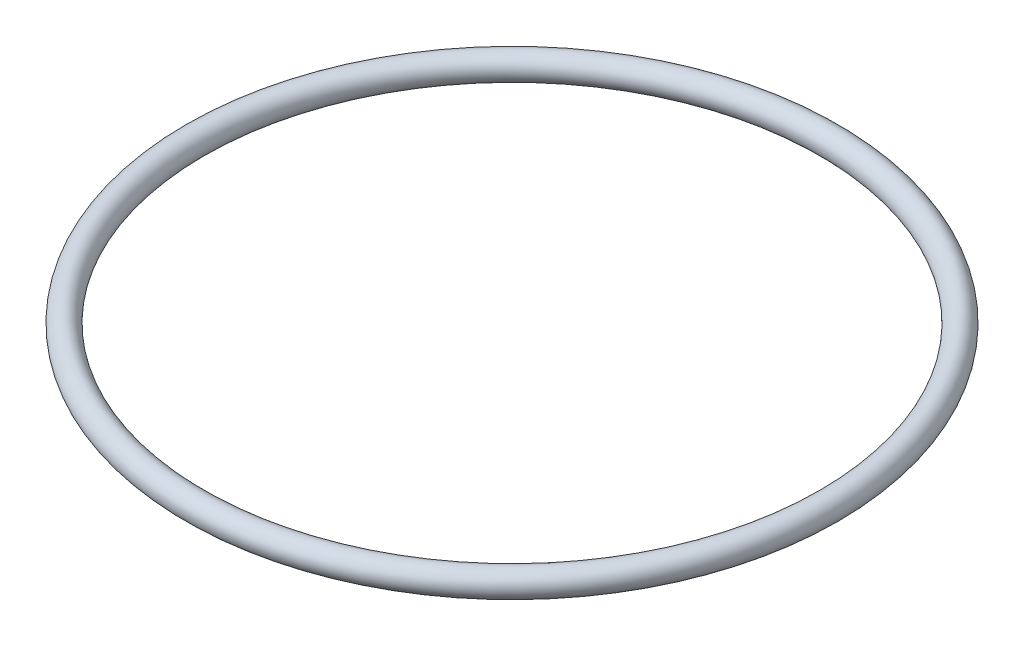
from build123d import *

# Parameters (mm, degrees)
SKETCH2_R = 1.3


with BuildPart() as part:
    # Sweep1: sweep along a path in Sketch1
    with BuildLine(Plane(origin=(0, 0, 0), x_dir=(1, 0, 0), z_dir=(0, 1, 0))) as sweep1_path:
        CenterArc((0, 0), 32.3, 0, 360)
    # Sketch2 → Sweep1 (sweep)
    with BuildSketch(Plane.XY):
        with Locations((-32.3, 0)):
            Circle(SKETCH2_R)
    sweep(path=sweep1_path.line)


solid = part.part
